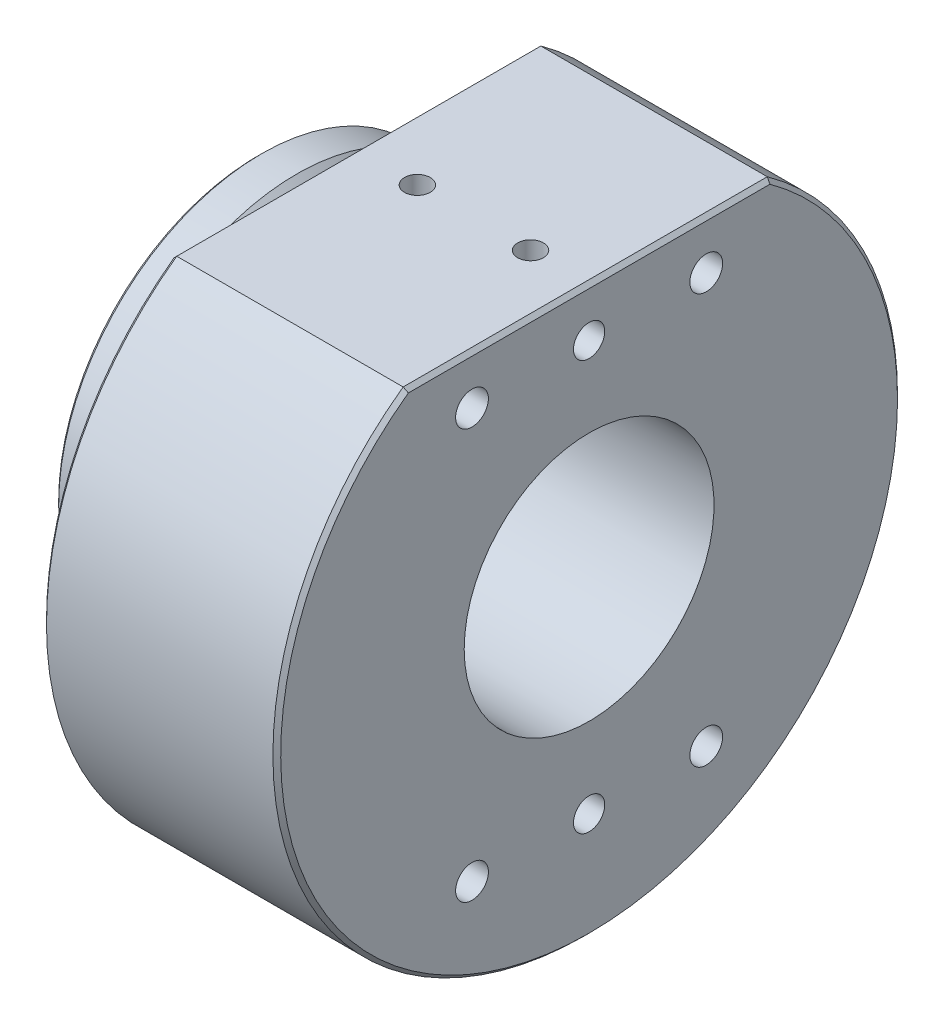
from build123d import *

# Parameters (mm, degrees)
CHAMFER1_SIZE                   = 0.5
SKETCH3_W                       = 30.914832272
SKETCH3_H                       = 82.011072724
CUT_EXTRUDE2_DEPTH              = 7.5
CHAMFER2_SIZE                   = 0.5
F_3_16_0_1875_DOWEL_HOLE1_D     = 4.7625
F_3_16_0_1875_DOWEL_HOLE1_DEPTH = 5.5
F_3_16_0_1875_DOWEL_HOLE1_TIP   = 1.430799349
M5X0_8_TAPPED_HOLE1_D           = 4.2
M5X0_8_TAPPED_HOLE1_DEPTH       = 12.4
M5X0_8_TAPPED_HOLE1_TIP         = 1.2618073
F_4_0MM_DOWEL_HOLE1_D           = 4
F_4_0MM_DOWEL_HOLE1_DEPTH       = 5.2
F_4_0MM_DOWEL_HOLE1_TIP         = 1.201721238
M4X0_7_TAPPED_HOLE1_REACH       = 89.275
M4X0_7_TAPPED_HOLE1_BORE_R      = 1.65


with BuildPart() as part:
    # Sketch1 → Revolve1 (revolve)
    with BuildSketch(Plane.XY, mode=Mode.PRIVATE) as revolve1_sk:
        Polygon((-27.58192079, 26), (-22.58192079, 26), (-19.361510024, 22.779589234), (-16.141099258, 26), (-15.141099258, 26), (-15.141099258, 40), (14.858900742, 40), (14.858900742, 16), (-27.58192079, 16), align=None)
    revolve(revolve1_sk.sketch.rotate(Axis((-39.738562092, 0, 0), (1, 0, 0)), 90), axis=Axis((-39.738562092, 0, 0), (1, 0, 0)))

    # Chamfer1
    chamfer1_edges = [part.edges().sort_by_distance(p)[0] for p in [
        (-27.58192079, 0, -26),
        (14.858900742, 0, -40),
        (-15.141099258, 0, -40),
    ]]
    chamfer(chamfer1_edges, length=CHAMFER1_SIZE)

    # Sketch3 → Cut-Extrude2 (cut)
    with BuildSketch(Plane(origin=(0, 40, 0), x_dir=(1, 0, 0), z_dir=(0, 1, 0))):
        with Locations((-0.069893973, 0.224952002)):
            Rectangle(SKETCH3_W, SKETCH3_H)
    extrude(amount=-CUT_EXTRUDE2_DEPTH, mode=Mode.SUBTRACT)

    # Chamfer2
    chamfer2_edges = [part.edges().sort_by_distance(p)[0] for p in [
        (14.858900742, 32.5, 0),
        (-15.141099258, 32.5, 0),
    ]]
    chamfer(chamfer2_edges, length=CHAMFER2_SIZE)

    # 3/16 (0.1875) Dowel Hole1
    with Locations(Plane.ZY.offset(15.141099258)):
        with Locations((0, 29)):
            Hole(F_3_16_0_1875_DOWEL_HOLE1_D / 2, depth=F_3_16_0_1875_DOWEL_HOLE1_DEPTH)
            with Locations((0, 0, -(F_3_16_0_1875_DOWEL_HOLE1_DEPTH + F_3_16_0_1875_DOWEL_HOLE1_TIP / 2))):  # 118° drill point
                Cone(0, F_3_16_0_1875_DOWEL_HOLE1_D / 2, F_3_16_0_1875_DOWEL_HOLE1_TIP, mode=Mode.SUBTRACT)

    # M5x0.8 Tapped Hole1
    with Locations(Plane(origin=(14.858900742, 0, 0), x_dir=(0, 0, -1), z_dir=(1, 0, 0))):
        with Locations((-15, 26.25), (15, 26.25), (-15, -26.25), (15, -26.25)):
            Hole(M5X0_8_TAPPED_HOLE1_D / 2, depth=M5X0_8_TAPPED_HOLE1_DEPTH)
            with Locations((0, 0, -(M5X0_8_TAPPED_HOLE1_DEPTH + M5X0_8_TAPPED_HOLE1_TIP / 2))):  # 118° drill point
                Cone(0, M5X0_8_TAPPED_HOLE1_D / 2, M5X0_8_TAPPED_HOLE1_TIP, mode=Mode.SUBTRACT)

    # Ø4.0mm Dowel Hole1
    with Locations(Plane(origin=(14.858900742, 0, 0), x_dir=(0, 0, -1), z_dir=(1, 0, 0))):
        with Locations((0, 26.25), (0, -26.25)):
            Hole(F_4_0MM_DOWEL_HOLE1_D / 2, depth=F_4_0MM_DOWEL_HOLE1_DEPTH)
            with Locations((0, 0, -(F_4_0MM_DOWEL_HOLE1_DEPTH + F_4_0MM_DOWEL_HOLE1_TIP / 2))):  # 118° drill point
                Cone(0, F_4_0MM_DOWEL_HOLE1_D / 2, F_4_0MM_DOWEL_HOLE1_TIP, mode=Mode.SUBTRACT)

    # M4x0.7 Tapped Hole1 bore → M4x0.7 Tapped Hole1 (cut, up to next)
    with BuildSketch(Plane(origin=(0, 32.5, 0), x_dir=(1, 0, 0), z_dir=(0, 1, 0)), mode=Mode.PRIVATE) as m4x0_7_tapped_hole1_sk1:
        with Locations((-7.141099258, 0)):
            Circle(M4X0_7_TAPPED_HOLE1_BORE_R)
    m4x0_7_tapped_hole1_tool1 = extrude(m4x0_7_tapped_hole1_sk1.sketch, amount=-M4X0_7_TAPPED_HOLE1_REACH, mode=Mode.PRIVATE) & part.part
    # M4x0.7 Tapped Hole1 bore → M4x0.7 Tapped Hole1 (cut, up to next)
    with BuildSketch(Plane(origin=(0, 32.5, 0), x_dir=(1, 0, 0), z_dir=(0, 1, 0)), mode=Mode.PRIVATE) as m4x0_7_tapped_hole1_sk2:
        with Locations((7.358900742, 0)):
            Circle(M4X0_7_TAPPED_HOLE1_BORE_R)
    m4x0_7_tapped_hole1_tool2 = extrude(m4x0_7_tapped_hole1_sk2.sketch, amount=-M4X0_7_TAPPED_HOLE1_REACH, mode=Mode.PRIVATE) & part.part
    add(m4x0_7_tapped_hole1_tool1.solids().sort_by_distance((-7.141099, 32.5, 0))[0], mode=Mode.SUBTRACT)
    add(m4x0_7_tapped_hole1_tool2.solids().sort_by_distance((7.358901, 32.5, 0))[0], mode=Mode.SUBTRACT)


solid = part.part
